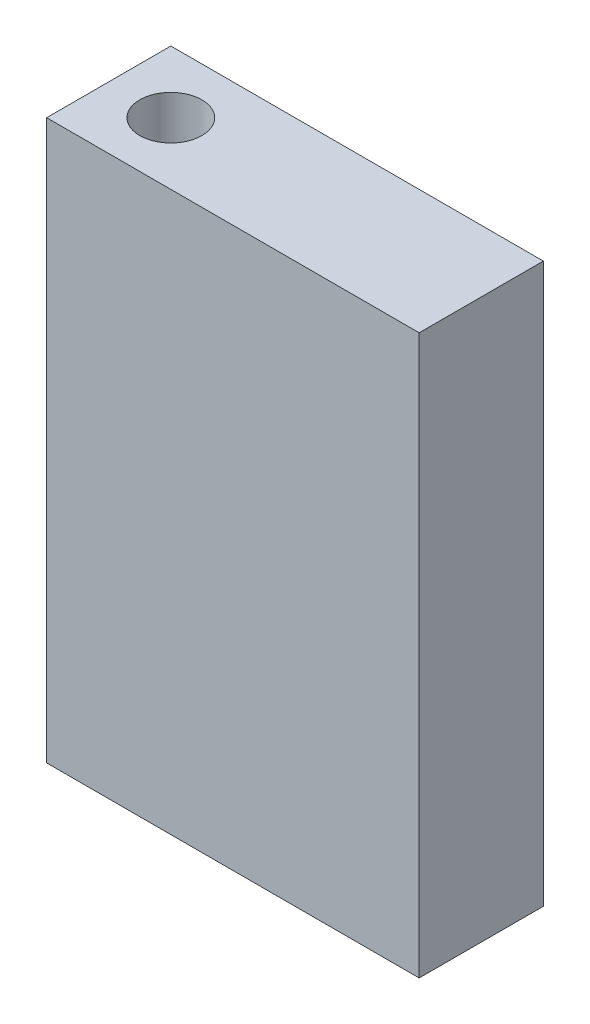
from build123d import *

# Parameters (mm, degrees)
SKETCH1_W           = 30
SKETCH1_H           = 10
BOSS_EXTRUDE1_DEPTH = 45
SKETCH2_R           = 2.5
CUT_EXTRUDE1_DEPTH  = 35


with BuildPart() as part:
    # Sketch1 → Boss-Extrude1 (new body)
    with BuildSketch(Plane(origin=(0, 0, 0), x_dir=(1, 0, 0), z_dir=(0, 1, 0))):
        with Locations((-8.020657094, 22.330303449)):
            Rectangle(SKETCH1_W, SKETCH1_H)
    extrude(amount=BOSS_EXTRUDE1_DEPTH)

    # Sketch2 → Cut-Extrude1 (cut)
    with BuildSketch(Plane(origin=(0, 45, 0), x_dir=(1, 0, 0), z_dir=(0, 1, 0))):
        with Locations((-18.020657094, 22.330303449)):
            Circle(SKETCH2_R)
    extrude(amount=-CUT_EXTRUDE1_DEPTH, mode=Mode.SUBTRACT)


solid = part.part
